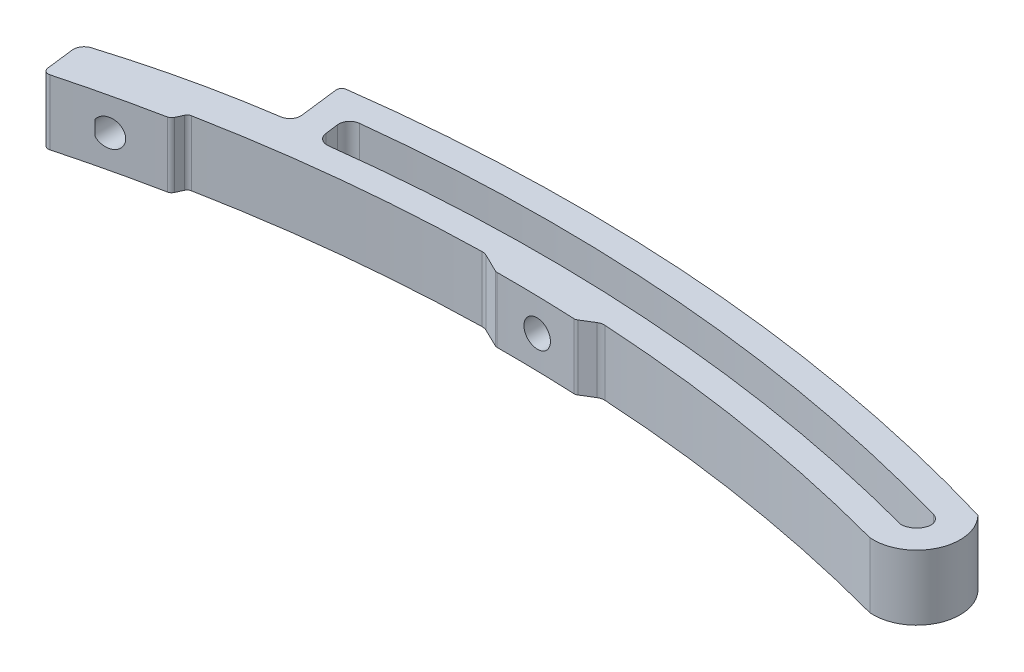
from build123d import *

# Parameters (mm, degrees)
BOSS_EXTRUDE1_DEPTH = 12
FILLET4_R           = 1
FILLET5_R           = 2
FILLET6_R           = 2
CUT_EXTRUDE3_DEPTH  = 33
FILLET8_R           = 2
BOSS_EXTRUDE2_DEPTH = 12
FILLET9_R           = 1
FILLET10_R          = 1
BOSS_EXTRUDE3_DEPTH = 12
FILLET11_R          = 2
FILLET12_R          = 1
FILLET13_R          = 2
SKETCH10_R          = 2.5
CUT_EXTRUDE4_DEPTH  = 18


with BuildPart() as part:
    # Sketch2 → Boss-Extrude1 (new body)
    with BuildSketch(Plane(origin=(0, 0, 0), x_dir=(1, 0, 0), z_dir=(0, 1, 0))):
        with BuildLine():
            Line((0, 0), (-0.73121606, 5.95527691))
            ThreePointArc((-0.73121606, 5.95527691), (15.138799382, 10.254914459), (31.320769044, 13.168354193))
            Line((31.320769044, 13.168354193), (30.087748344, 23.210501924))
            ThreePointArc((30.087748344, 23.210501924), (94.266191099, 25.160742626), (157.417218543, 13.557997867))
            ThreePointArc((157.417218543, 13.557997867), (158.923283556, 4.547467734), (151, 0))
            ThreePointArc((151, 0), (75.5, 10), (0, 0))
        make_face()
    extrude(amount=BOSS_EXTRUDE1_DEPTH)

    # Fillet4
    fillet4_edges = [part.edges().sort_by_distance(p)[0] for p in [
        (30.087748344, 6, -23.210501924),
    ]]
    fillet(fillet4_edges, radius=FILLET4_R)

    # Fillet5
    fillet5_edges = [part.edges().sort_by_distance(p)[0] for p in [
        (31.320769044, 6, -13.168354193),
    ]]
    fillet(fillet5_edges, radius=FILLET5_R)

    # Fillet6
    fillet6_edges = [part.edges().sort_by_distance(p)[0] for p in [
        (-0.73121606, 6, -5.95527691),
    ]]
    fillet(fillet6_edges, radius=FILLET6_R)

    # Sketch5 → Cut-Extrude3 (cut)
    with BuildSketch(Plane(origin=(0, 0, 0), x_dir=(1, 0, 0), z_dir=(0, 1, 0))):
        with BuildLine():
            Line((35.656168792, 18.886901985), (36.452121023, 12.404391276))
            ThreePointArc((36.452121023, 12.404391276), (94.477597701, 14.388970685), (151.768043541, 4.970939327))
            ThreePointArc((151.768043541, 4.970939327), (153.480302105, 5.560994433), (154.540953062, 7.028991016))
            ThreePointArc((154.540953062, 7.028991016), (154.409459032, 8.592099199), (153.190642938, 9.579563223))
            ThreePointArc((153.190642938, 9.579563223), (94.887793134, 20.097584909), (35.656168792, 18.886901985))
        make_face()
    extrude(amount=CUT_EXTRUDE3_DEPTH, mode=Mode.SUBTRACT)

    # Fillet8
    fillet8_edges = [part.edges().sort_by_distance(p)[0] for p in [
        (35.656168792, 6, -18.886901985),
        (36.452121023, 6, -12.404391276),
    ]]
    fillet(fillet8_edges, radius=FILLET8_R)

    # Sketch6 → Boss-Extrude2 (add)
    with BuildSketch(Plane(origin=(0, 0, 0), x_dir=(1, 0, 0), z_dir=(0, 1, 0))):
        with BuildLine():
            Line((0, 0), (0.243738687, -1.985092303))
            ThreePointArc((0.243738687, -1.985092303), (9.813572193, 0.430074334), (19.460534614, 2.515945677))
            Line((19.460534614, 2.515945677), (20.460534614, 4.729325881))
            ThreePointArc((20.460534614, 4.729325881), (10.187446562, 2.549918803), (0, 0))
        make_face()
    extrude(amount=BOSS_EXTRUDE2_DEPTH)

    # Fillet9
    fillet9_edges = [part.edges().sort_by_distance(p)[0] for p in [
        (0.243738687, 6, 1.985092303),
    ]]
    fillet(fillet9_edges, radius=FILLET9_R)

    # Fillet10
    fillet10_edges = [part.edges().sort_by_distance(p)[0] for p in [
        (20.460534614, 6, -4.729325881),
        (19.460534614, 6, -2.515945677),
    ]]
    fillet(fillet10_edges, radius=FILLET10_R)

    # Sketch7 → Boss-Extrude3 (add)
    with BuildSketch(Plane(origin=(0, 0, 0), x_dir=(1, 0, 0), z_dir=(0, 1, 0))):
        with BuildLine():
            Line((70, 9.947842385), (74, 7.996093893))
            ThreePointArc((74, 7.996093893), (81.502036249, 7.937453494), (89, 7.683433507))
            Line((89, 7.683433507), (92, 9.530243228))
            ThreePointArc((92, 9.530243228), (81.003961961, 9.947767207), (70, 9.947842385))
        make_face()
    extrude(amount=BOSS_EXTRUDE3_DEPTH)

    # Fillet11
    fillet11_edges = [part.edges().sort_by_distance(p)[0] for p in [
        (70, 6, -9.947842385),
    ]]
    fillet(fillet11_edges, radius=FILLET11_R)

    # Fillet12
    fillet12_edges = [part.edges().sort_by_distance(p)[0] for p in [
        (74, 6, -7.996093893),
        (89, 6, -7.683433507),
    ]]
    fillet(fillet12_edges, radius=FILLET12_R)

    # Fillet13
    fillet13_edges = [part.edges().sort_by_distance(p)[0] for p in [
        (92, 6, -9.530243228),
    ]]
    fillet(fillet13_edges, radius=FILLET13_R)

    # Sketch10 → Cut-Extrude4 (cut)
    with BuildSketch(Plane.XY):
        with Locations((81.692531177, 6)):
            Circle(SKETCH10_R)
        with Locations((10.103466275, 6)):
            Circle(SKETCH10_R)
    extrude(amount=-CUT_EXTRUDE4_DEPTH, mode=Mode.SUBTRACT)


solid = part.part
